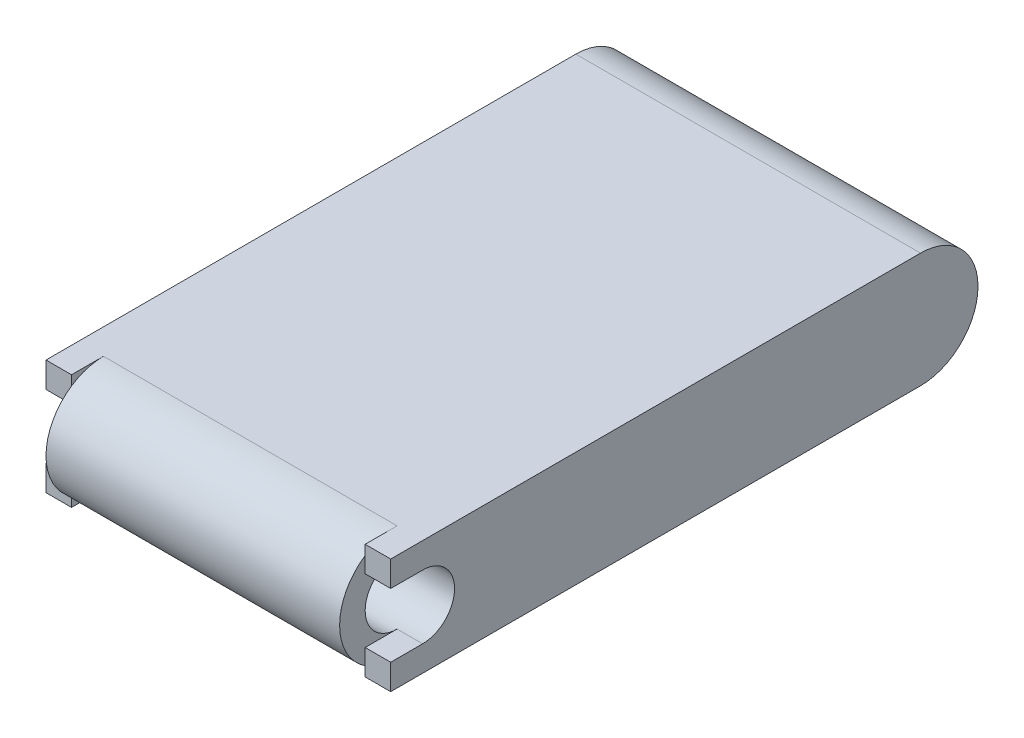
from build123d import *

# Parameters (mm, degrees)
SKETCH1_R                = 2.01676
BOSS_EXTRUDE2_DEPTH      = 10.88771
BOSS_EXTRUDE2_DEPTH_BACK = 10.88771
SKETCH2_R                = 3.62966
CUT_EXTRUDE1_DEPTH       = 1.6129
BOSS_EXTRUDE3_DEPTH      = 1.6129


with BuildPart() as part:
    # Sketch1 → Boss-Extrude2 (new body, two sides)
    with BuildSketch(Plane(origin=(0, 0, 0), x_dir=(0, 0, -1), z_dir=(1, 0, 0))) as boss_extrude2_sk:
        with BuildLine():
            Line((-15.72768, 3.62966), (15.72768, 3.62966))
            ThreePointArc((15.72768, 3.62966), (19.35734, 0), (15.72768, -3.62966))
            Line((15.72768, -3.62966), (-15.72768, -3.62966))
            ThreePointArc((-15.72768, -3.62966), (-19.35734, 0), (-15.72768, 3.62966))
        make_face()
        with Locations((-15.72768, 0)):
            Circle(SKETCH1_R, mode=Mode.SUBTRACT)
    extrude(amount=BOSS_EXTRUDE2_DEPTH)
    extrude(boss_extrude2_sk.sketch, amount=-BOSS_EXTRUDE2_DEPTH_BACK)

    # Sketch2 → Cut-Extrude1 (cut)
    with BuildSketch(Plane(origin=(10.88771, 0, 0), x_dir=(0, 0, -1), z_dir=(1, 0, 0))):
        with Locations((-15.72768, 0)):
            Circle(SKETCH2_R)
    cut_extrude1 = extrude(amount=-CUT_EXTRUDE1_DEPTH, mode=Mode.SUBTRACT)

    # Mirror1: Cut-Extrude1 across plane
    add(cut_extrude1.mirror(Plane(origin=(0, 0, 0), x_dir=(0, 0, 1), z_dir=(1, 0, 0))), mode=Mode.SUBTRACT)

    # Sketch3 → Boss-Extrude3 (add)
    with BuildSketch(Plane(origin=(10.88771, 0, 0), x_dir=(0, 0, -1), z_dir=(1, 0, 0))):
        with BuildLine():
            Line((-17.74444, -2.01676), (-17.74444, -3.62966))
            Line((-17.74444, -3.62966), (-15.72768, -3.62966))
            ThreePointArc((-15.72768, -3.62966), (-12.09802, 0), (-15.72768, 3.62966))
            Line((-15.72768, 3.62966), (-17.74444, 3.62966))
            Line((-17.74444, 3.62966), (-17.74444, 2.01676))
            Line((-17.74444, 2.01676), (-15.72768, 2.01676))
            ThreePointArc((-15.72768, 2.01676), (-13.71092, 0), (-15.72768, -2.01676))
            Line((-15.72768, -2.01676), (-17.74444, -2.01676))
        make_face()
    boss_extrude3 = extrude(amount=-BOSS_EXTRUDE3_DEPTH)

    # Mirror2: Boss-Extrude3 across plane
    add(boss_extrude3.mirror(Plane(origin=(0, 0, 0), x_dir=(0, 0, 1), z_dir=(1, 0, 0))))


solid = part.part
